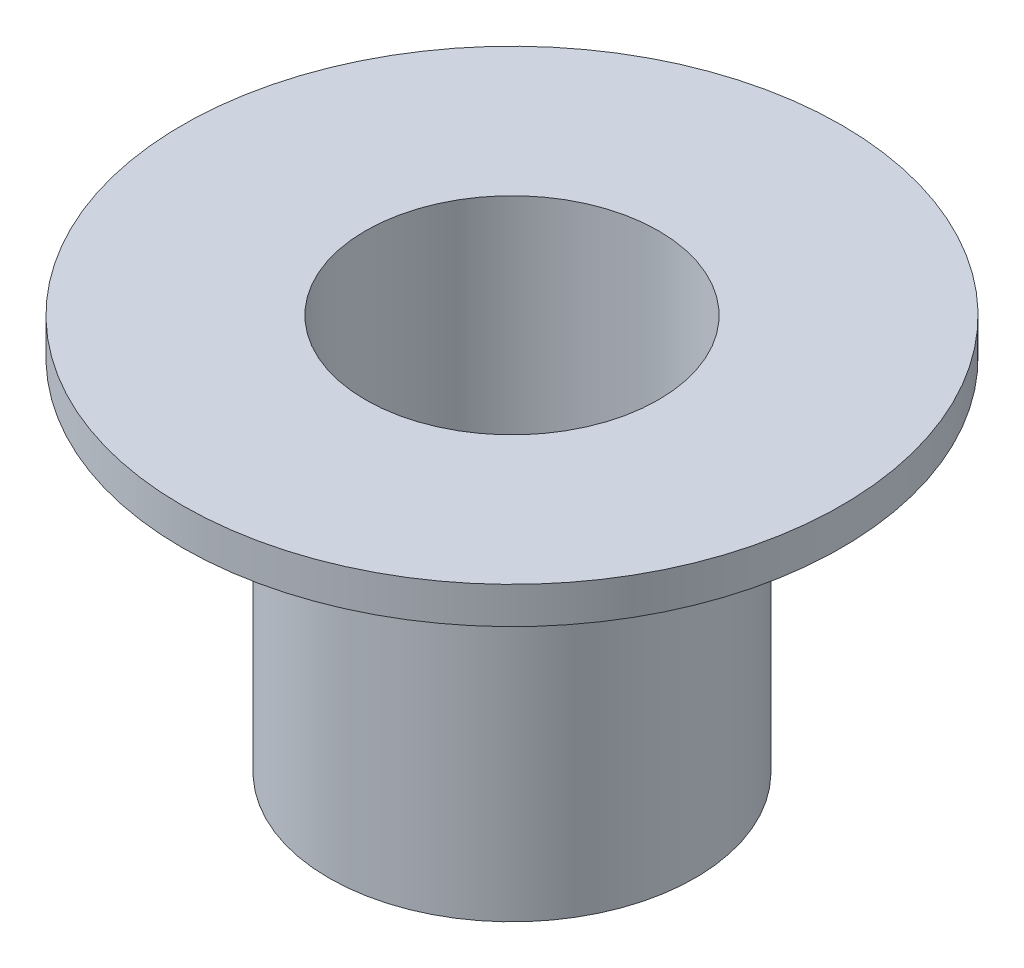
from build123d import *

# Parameters (mm, degrees)
SKETCH1_R           = 5
BOSS_EXTRUDE1_DEPTH = 9.81
SKETCH2_R           = 9
BOSS_EXTRUDE2_DEPTH = 1
SKETCH3_R           = 4
CUT_EXTRUDE1_DEPTH  = 15.72


with BuildPart() as part:
    # Sketch1 → Boss-Extrude1 (new body)
    with BuildSketch(Plane(origin=(0, 0, 0), x_dir=(1, 0, 0), z_dir=(0, 1, 0))):
        Circle(SKETCH1_R)
    extrude(amount=-BOSS_EXTRUDE1_DEPTH)

    # Sketch2 → Boss-Extrude2 (add)
    with BuildSketch(Plane(origin=(0, 0, 0), x_dir=(1, 0, 0), z_dir=(0, 1, 0))):
        Circle(SKETCH2_R)
    extrude(amount=BOSS_EXTRUDE2_DEPTH)

    # Sketch3 → Cut-Extrude1 (cut)
    with BuildSketch(Plane(origin=(0, 1, 0), x_dir=(1, 0, 0), z_dir=(0, 1, 0))):
        Circle(SKETCH3_R)
    extrude(amount=-CUT_EXTRUDE1_DEPTH, mode=Mode.SUBTRACT)


solid = part.part
